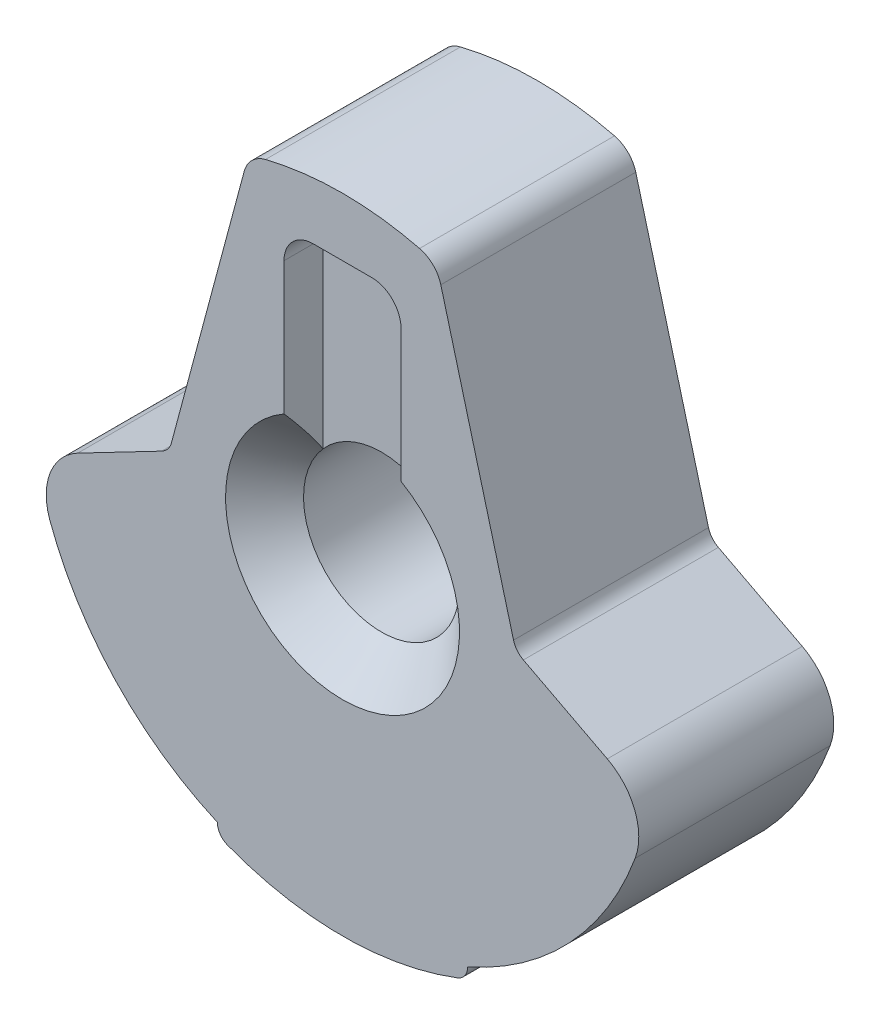
from build123d import *

# Parameters (mm, degrees)
EXTRUDE1_DEPTH  = 2.54
EXTRUDE2_DEPTH  = 3.54
EXTRUDE3_DEPTH  = 3.54
FILLET1_R       = 0.762
SKETCH6_R       = 1.016
EXTRUDE6_DEPTH  = 3.54
EXTRUDE9_DEPTH  = 0.508
EXTRUDE10_DEPTH = 0.508


with BuildPart() as part:
    # Sketch1 → Extrude1 (new body)
    with BuildSketch(Plane.XY):
        with BuildLine():
            Line((-3.682902029, 0.407863494), (-2.38382675, 0.407863494))
            ThreePointArc((-2.38382675, 0.407863494), (-2.229201347, 0.460351745), (-2.13848159, 0.596123456))
            Line((-2.13848159, 0.596123456), (-1.280622225, 3.797698194))
            ThreePointArc((-1.280622225, 3.797698194), (-1.179315691, 3.971165577), (-1.003864933, 4.068996952))
            ThreePointArc((-1.003864933, 4.068996952), (0, 4.191), (1.003864933, 4.068996952))
            ThreePointArc((1.003864933, 4.068996952), (1.179315691, 3.971165577), (1.280622225, 3.797698194))
            Line((1.280622225, 3.797698194), (2.13848159, 0.596123456))
            ThreePointArc((2.13848159, 0.596123456), (2.229201347, 0.460351745), (2.38382675, 0.407863494))
            Line((2.38382675, 0.407863494), (3.682902029, 0.407863494))
            ThreePointArc((3.682902029, 0.407863494), (3.951325396, 0.297251911), (4.063891894, 0.029642476))
            ThreePointArc((4.063891894, 0.029642476), (3.409731918, -2.2112947), (1.63048159, -3.722583214))
            ThreePointArc((1.63048159, -3.722583214), (1.594432949, -3.838601921), (1.498982382, -3.913761978))
            ThreePointArc((1.498982382, -3.913761978), (0, -4.191), (-1.498982382, -3.913761978))
            ThreePointArc((-1.498982382, -3.913761978), (-1.594432949, -3.838601921), (-1.63048159, -3.722583214))
            ThreePointArc((-1.63048159, -3.722583214), (-3.409731918, -2.2112947), (-4.063891894, 0.029642476))
            ThreePointArc((-4.063891894, 0.029642476), (-3.951325396, 0.297251911), (-3.682902029, 0.407863494))
        make_face()
    extrude(amount=EXTRUDE1_DEPTH)

    # Sketch2 → Extrude2 (cut, through all)
    with BuildSketch(Plane.XY.offset(2.54)):
        with BuildLine():
            Line((-2.38382675, 0.407863494), (-3.682902029, 0.407863494))
            ThreePointArc((-3.682902029, 0.407863494), (-3.951325396, 0.297251911), (-4.063891894, 0.029642476))
            ThreePointArc((-4.063891894, 0.029642476), (-4.047838367, -0.362078102), (-3.994114692, -0.750429096))
            Line((-3.994114692, -0.750429096), (-2.356119493, 0.102257234))
            ThreePointArc((-2.356119493, 0.102257234), (-2.275312982, 0.168573423), (-2.228058481, 0.261817948))
            Line((-2.228058481, 0.261817948), (-2.13848159, 0.596123456))
            ThreePointArc((-2.13848159, 0.596123456), (-2.229201347, 0.460351745), (-2.38382675, 0.407863494))
        make_face()
    extrude(amount=-EXTRUDE2_DEPTH, mode=Mode.SUBTRACT)

    # Sketch3 → Extrude3 (cut, through all)
    with BuildSketch(Plane.XY.offset(2.54)):
        with BuildLine():
            Line((3.682902029, 0.407863494), (2.38382675, 0.407863494))
            ThreePointArc((2.38382675, 0.407863494), (2.229201347, 0.460351745), (2.13848159, 0.596123456))
            Line((2.13848159, 0.596123456), (2.228058481, 0.261817948))
            ThreePointArc((2.228058481, 0.261817948), (2.275312982, 0.168573423), (2.356119493, 0.102257234))
            Line((2.356119493, 0.102257234), (3.994114692, -0.750429096))
            ThreePointArc((3.994114692, -0.750429096), (4.047838367, -0.362078102), (4.063891894, 0.029642476))
            ThreePointArc((4.063891894, 0.029642476), (3.951325396, 0.297251911), (3.682902029, 0.407863494))
        make_face()
    extrude(amount=-EXTRUDE3_DEPTH, mode=Mode.SUBTRACT)

    # Fillet1
    fillet1_edges = [part.edges().sort_by_distance(p)[0] for p in [
        (-3.994114692, -0.750429096, 1.27),
        (3.994114692, -0.750429096, 1.27),
    ]]
    fillet(fillet1_edges, radius=FILLET1_R)

    # Sketch6 → Extrude6 (cut, through all)
    with BuildSketch(Plane.XY.offset(2.54)):
        Circle(SKETCH6_R)
    extrude(amount=-EXTRUDE6_DEPTH, mode=Mode.SUBTRACT)

    # Sketch11 → Cut-Revolve1 (revolve, cut)
    with BuildSketch(Plane(origin=(0, 0, 0), x_dir=(1, 0, 0), z_dir=(0, 1, 0))):
        Polygon((0, -2.54), (1.524, -2.54), (0.508, -1.524), (0.508, -1.016), (1.524, 0), (0, 0), align=None)
    revolve(axis=Axis((0, 0, 0), (0, 0, 1)), mode=Mode.SUBTRACT)

    # Sketch9 → Extrude9 (cut)
    with BuildSketch(Plane(origin=(0, 0, 0), x_dir=(-1, 0, 0), z_dir=(0, 0, -1))):
        with BuildLine():
            Line((-0.381, 3.429), (0.381, 3.429))
            ThreePointArc((0.381, 3.429), (0.650407684, 3.317407684), (0.762, 3.048))
            Line((0.762, 3.048), (0.762, 0.672020833))
            Line((0.762, 0.672020833), (-0.762, 0.672020833))
            Line((-0.762, 0.672020833), (-0.762, 3.048))
            ThreePointArc((-0.762, 3.048), (-0.650407684, 3.317407684), (-0.381, 3.429))
        make_face()
    extrude(amount=-EXTRUDE9_DEPTH, mode=Mode.SUBTRACT)

    # Sketch10 → Extrude10 (cut)
    with BuildSketch(Plane.XY.offset(2.54)):
        with BuildLine():
            Line((-0.381, 3.429), (0.381, 3.429))
            ThreePointArc((0.381, 3.429), (0.650407684, 3.317407684), (0.762, 3.048))
            Line((0.762, 3.048), (0.762, 0.672020833))
            Line((0.762, 0.672020833), (-0.762, 0.672020833))
            Line((-0.762, 0.672020833), (-0.762, 3.048))
            ThreePointArc((-0.762, 3.048), (-0.650407684, 3.317407684), (-0.381, 3.429))
        make_face()
    extrude(amount=-EXTRUDE10_DEPTH, mode=Mode.SUBTRACT)


solid = part.part
